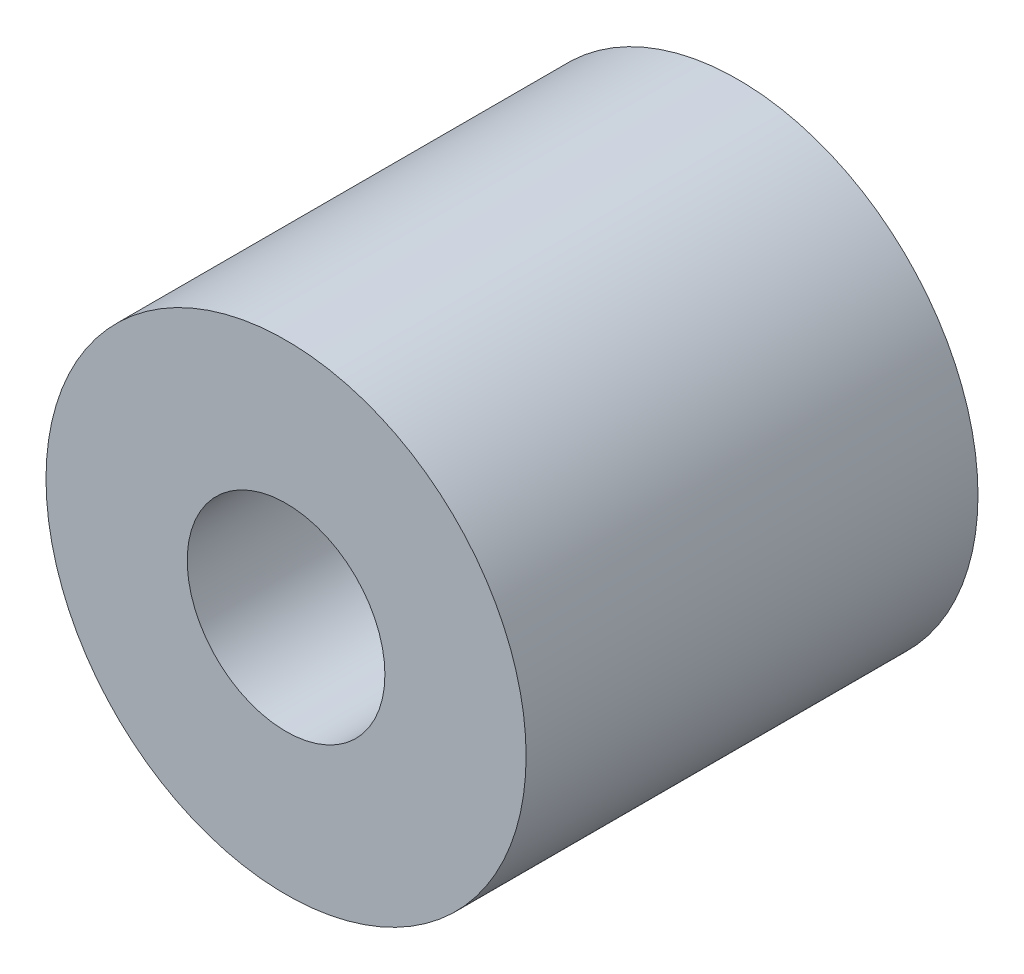
from build123d import *

# Parameters (mm, degrees)
SKETCH1_R           = 8.5
SKETCH1_R_2         = 3.5
BOSS_EXTRUDE1_DEPTH = 16


with BuildPart() as part:
    # Sketch1 → Boss-Extrude1 (new body)
    with BuildSketch(Plane.XY):
        Circle(SKETCH1_R)
        Circle(SKETCH1_R_2, mode=Mode.SUBTRACT)
    extrude(amount=BOSS_EXTRUDE1_DEPTH)


solid = part.part
